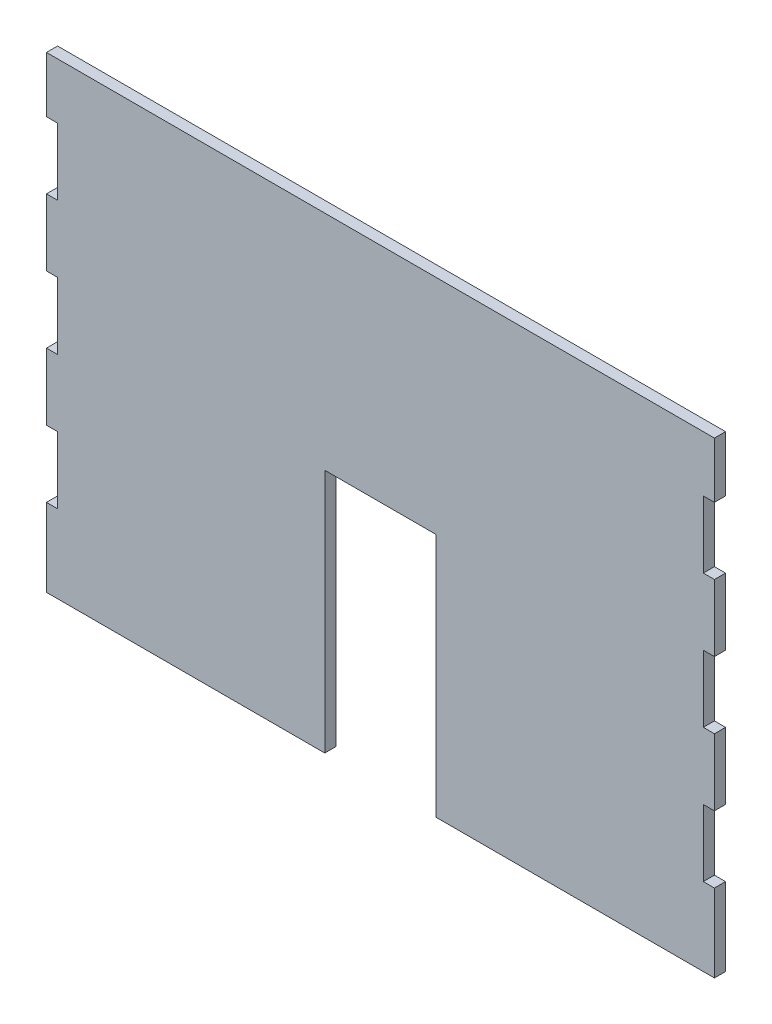
from build123d import *

# Parameters (mm, degrees)
SKETCH1_W           = 300
SKETCH1_H           = 210
BOSS_EXTRUDE1_DEPTH = 5
SKETCH2_W           = 67.619836516
SKETCH2_H           = 30
SKETCH2_W_2         = 72.619836516
SKETCH2_W_3         = 53.212613818
CUT_EXTRUDE1_DEPTH  = 6
SKETCH3_W           = 50
SKETCH3_H           = 110
CUT_EXTRUDE2_DEPTH  = 6


with BuildPart() as part:
    # Sketch1 → Boss-Extrude1 (new body)
    with BuildSketch(Plane.XY):
        Rectangle(SKETCH1_W, SKETCH1_H)
    extrude(amount=BOSS_EXTRUDE1_DEPTH)

    # Sketch2 → Cut-Extrude1 (cut, through all)
    with BuildSketch(Plane(origin=(0, 0, 0), x_dir=(-1, 0, 0), z_dir=(0, 0, -1))):
        with Locations((-178.809918258, 65)):
            Rectangle(SKETCH2_W, SKETCH2_H)
        with Locations((-181.309918258, 5)):
            Rectangle(SKETCH2_W_2, SKETCH2_H)
        with Locations((-181.309918258, -55)):
            Rectangle(SKETCH2_W_2, SKETCH2_H)
        with Locations((171.606306909, 65)):
            Rectangle(SKETCH2_W_3, SKETCH2_H)
        with Locations((181.309918258, 5)):
            Rectangle(SKETCH2_W_2, SKETCH2_H)
        with Locations((181.309918258, -55)):
            Rectangle(SKETCH2_W_2, SKETCH2_H)
    extrude(amount=-CUT_EXTRUDE1_DEPTH, mode=Mode.SUBTRACT)

    # Sketch3 → Cut-Extrude2 (cut, through all)
    with BuildSketch(Plane.XY.offset(5)):
        with Locations((0, -50)):
            Rectangle(SKETCH3_W, SKETCH3_H)
    extrude(amount=-CUT_EXTRUDE2_DEPTH, mode=Mode.SUBTRACT)


solid = part.part
